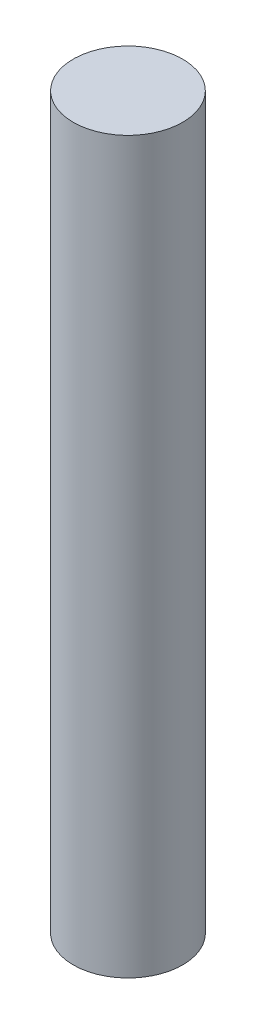
from build123d import *

# Parameters (mm, degrees)
SKETCH1_R           = 1.5
BOSS_EXTRUDE1_DEPTH = 20


with BuildPart() as part:
    # Sketch1 → Boss-Extrude1 (new body)
    with BuildSketch(Plane(origin=(0, 0, 0), x_dir=(1, 0, 0), z_dir=(0, 1, 0))):
        Circle(SKETCH1_R)
    extrude(amount=BOSS_EXTRUDE1_DEPTH)


solid = part.part
